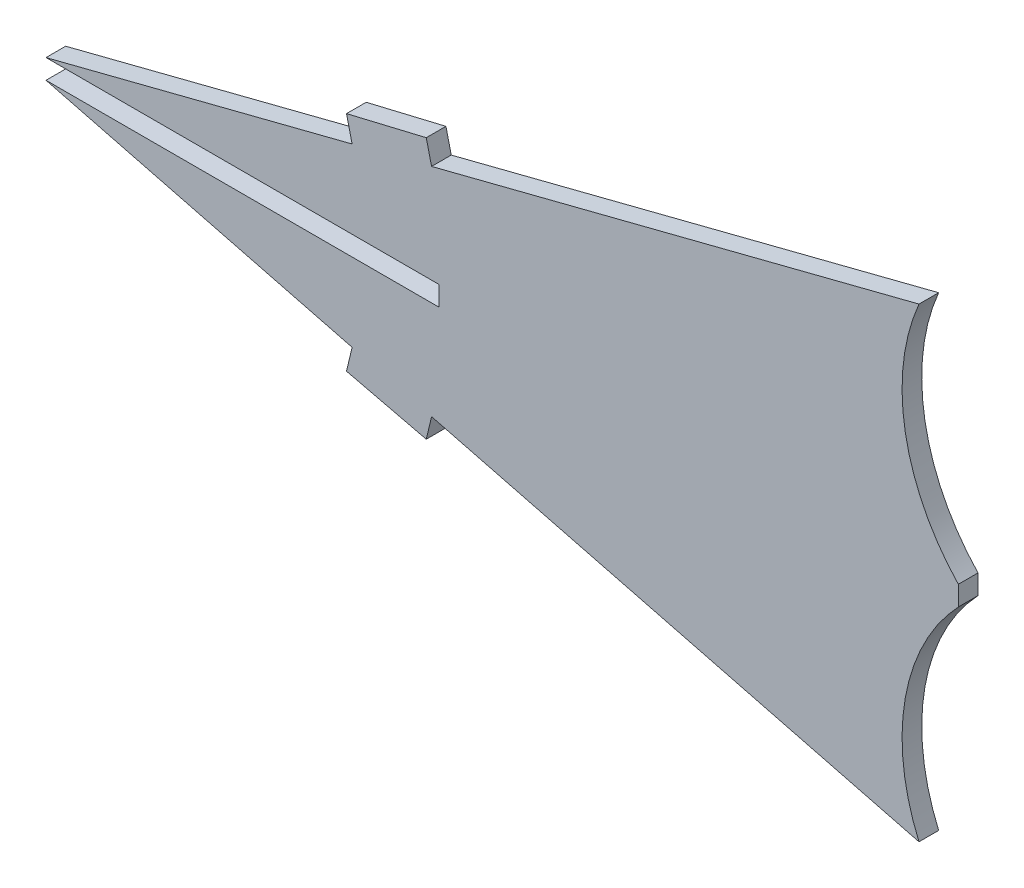
from build123d import *

# Parameters (mm, degrees)
BOSS_EXTRUDE1_DEPTH = 1.524


with BuildPart() as part:
    # Sketch1 → Boss-Extrude1 (new body)
    with BuildSketch(Plane.XY):
        with BuildLine():
            Line((150.036715568, -1.524), (150.036715568, 0))
            Line((150.036715568, 0), (119.605645903, 0))
            Line((119.605645903, 0), (143.313878366, 6.056634362))
            Line((143.313878366, 6.056634362), (142.879507781, 7.877232472))
            Line((142.879507781, 7.877232472), (149.056142524, 9.350895679))
            Line((149.056142524, 9.350895679), (149.467068546, 7.628561883))
            Line((149.467068546, 7.628561883), (187.215425718, 17.271963073))
            ThreePointArc((187.215425718, 17.271963073), (186.146982613, 8.178774912), (190.262232611, 0))
            Line((190.262232611, 0), (190.262232611, -1.524))
            ThreePointArc((190.262232611, -1.524), (186.146982613, -9.702774912), (187.215425718, -18.795963073))
            Line((187.215425718, -18.795963073), (149.467068546, -9.152561883))
            Line((149.467068546, -9.152561883), (149.056142524, -10.874895679))
            Line((149.056142524, -10.874895679), (142.879507781, -9.401232472))
            Line((142.879507781, -9.401232472), (143.313878366, -7.580634362))
            Line((143.313878366, -7.580634362), (119.605645903, -1.524))
            Line((119.605645903, -1.524), (150.036715568, -1.524))
        make_face()
    extrude(amount=BOSS_EXTRUDE1_DEPTH)


solid = part.part
